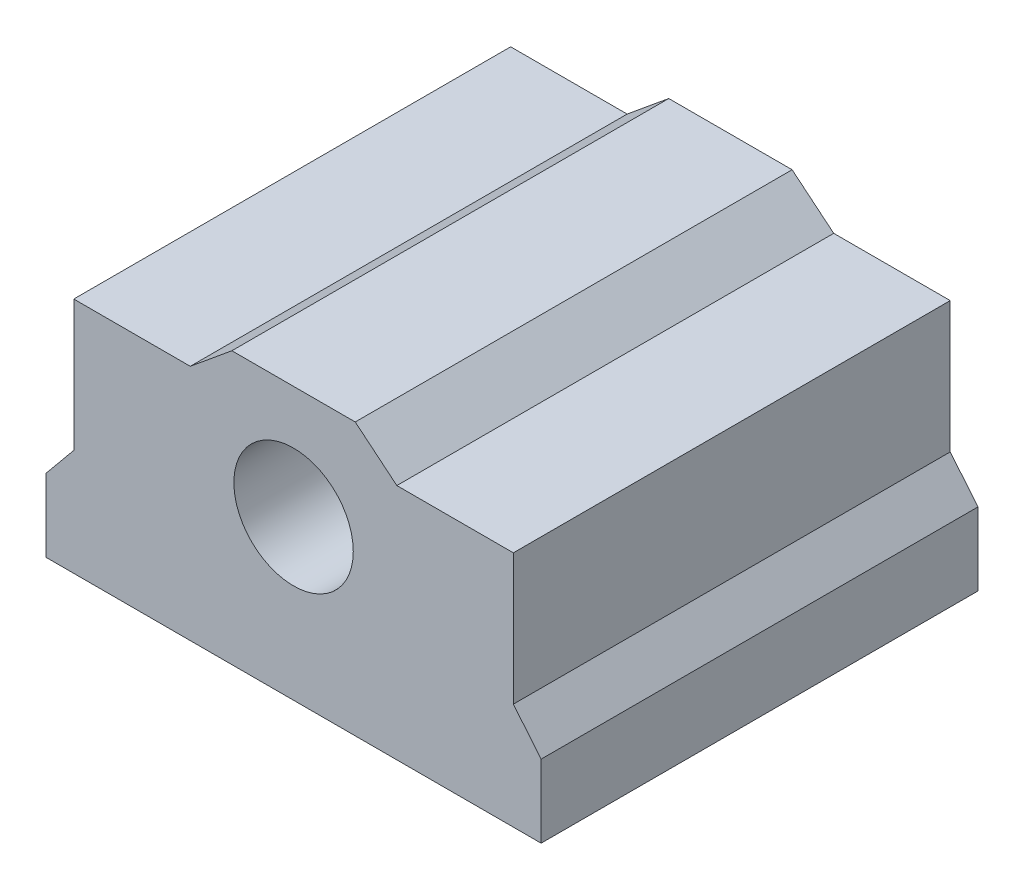
from build123d import *

# Parameters (mm, degrees)
SKETCH1_R           = 4.1
BOSS_EXTRUDE1_DEPTH = 30


with BuildPart() as part:
    # Sketch1 → Boss-Extrude1 (new body)
    with BuildSketch(Plane.XY):
        Polygon((-17, 0), (17, 0), (17, 5), (15.092720297, 7.315660626), (15.092720297, 16.315660626), (7.092720297, 16.315660626), (4.235856973, 18.668698619), (-4.235856973, 18.668698619), (-7.092720297, 16.315660626), (-15.092720297, 16.315660626), (-15.092720297, 7.315660626), (-17, 5), align=None)
        with Locations((0, 10.9)):
            Circle(SKETCH1_R, mode=Mode.SUBTRACT)
    extrude(amount=BOSS_EXTRUDE1_DEPTH)


solid = part.part
